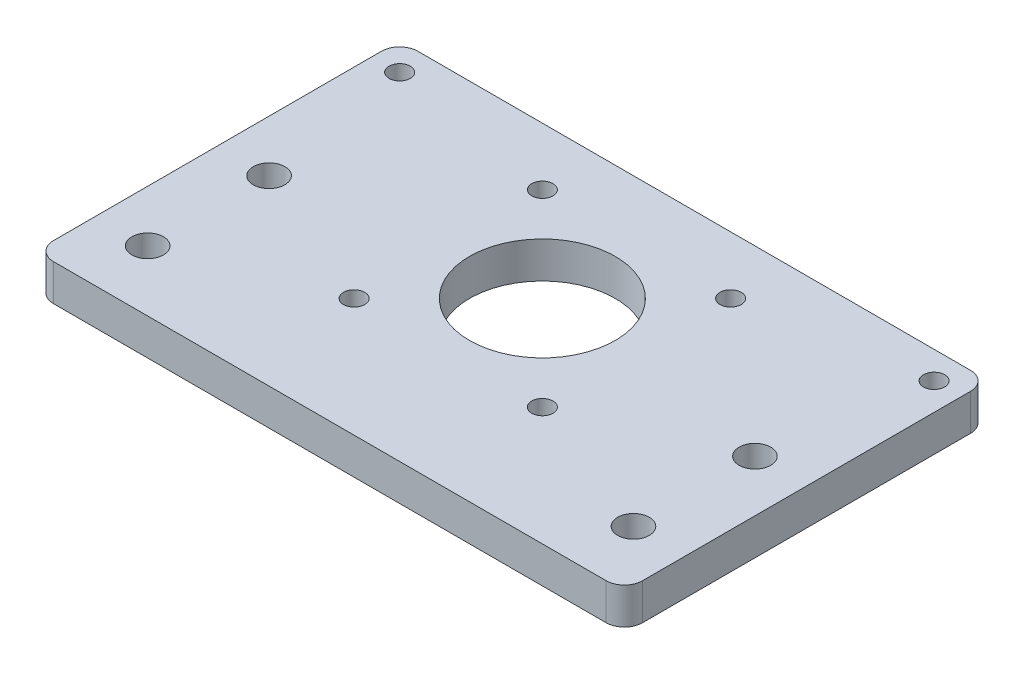
from build123d import *

# Parameters (mm, degrees)
SKETCH1_W                     = 97
SKETCH1_H                     = 60
BASE_DEPTH                    = 6
SKETCH2_R                     = 12
STEPPERCASEHOLE_DEPTH         = 7
FILLETEDGES3MM_R              = 3
F_3_5MM_CABLETIEHOLES_D       = 3.5
F_5_2_5_2_HOLESFORCORNERS_D   = 5.2
F_3_5_3_5_STEPPERMOUNTHOLES_D = 3.5


with BuildPart() as part:
    # Sketch1 → Base (new body)
    with BuildSketch(Plane(origin=(0, 0, 0), x_dir=(1, 0, 0), z_dir=(0, 1, 0))):
        Rectangle(SKETCH1_W, SKETCH1_H)
    extrude(amount=BASE_DEPTH)

    # Sketch2 → StepperCaseHole (cut, through all)
    with BuildSketch(Plane(origin=(0, 6, 0), x_dir=(1, 0, 0), z_dir=(0, 1, 0))):
        with Locations((0, 5)):
            Circle(SKETCH2_R)
    extrude(amount=-STEPPERCASEHOLE_DEPTH, mode=Mode.SUBTRACT)

    # FilletEdges3mm
    filletedges3mm_edges = [part.edges().sort_by_distance(p)[0] for p in [
        (-48.5, 3, -30),
        (48.5, 3, -30),
        (48.5, 3, 30),
        (-48.5, 3, 30),
    ]]
    fillet(filletedges3mm_edges, radius=FILLETEDGES3MM_R)

    # Ø3.5mm CableTieHoles (through all)
    with Locations(Plane(origin=(0, 0, 0), x_dir=(-1, 0, 0), z_dir=(0, -1, 0))):
        with Locations((-44, 25.5), (44, 25.5)):
            Hole(F_3_5MM_CABLETIEHOLES_D / 2)

    # Ø5.2 (5.2) HolesForCorners (through all)
    with Locations(Plane(origin=(0, 6, 0), x_dir=(1, 0, 0), z_dir=(0, 1, 0))):
        with Locations((-40, 0), (-40, -20), (40, 0), (40, -20)):
            Hole(F_5_2_5_2_HOLESFORCORNERS_D / 2)

    # Ø3.5 (3.5) StepperMountHoles (through all)
    with Locations(Plane(origin=(0, 6, 0), x_dir=(1, 0, 0), z_dir=(0, 1, 0))):
        with Locations((-15.5, 20.5), (-15.5, -10.5), (15.5, -10.5), (15.5, 20.5)):
            Hole(F_3_5_3_5_STEPPERMOUNTHOLES_D / 2)


solid = part.part
